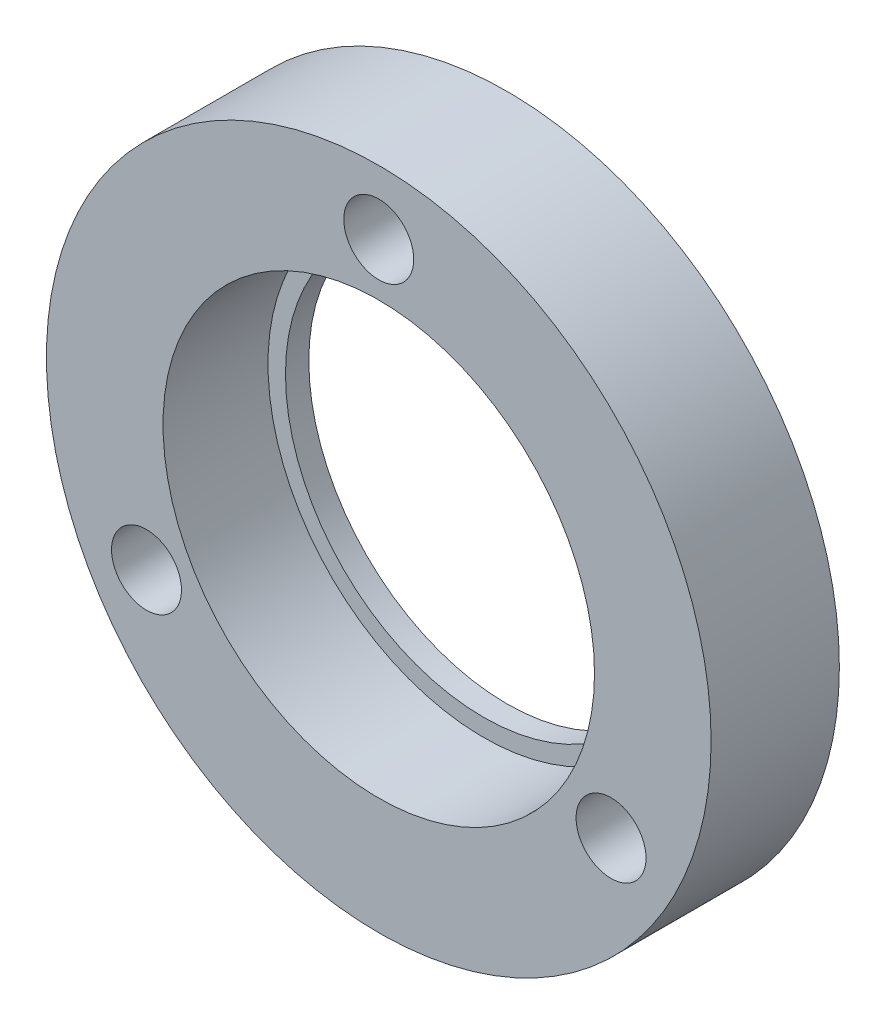
from build123d import *

# Parameters (mm, degrees)
SKETCH_1_R          = 28.5
EXTRUDE_1_DEPTH     = 11
SKETCH_3_R          = 18.5
CUT_EXTRUDE_1_DEPTH = 9
SKETCH_4_R          = 17
CUT_EXTRUDE_2_DEPTH = 3
SKETCH_5_R          = 3
CUT_EXTRUDE_3_DEPTH = 12


with BuildPart() as part:
    # 草图1 → 凸台-拉伸1 (new body)
    with BuildSketch(Plane.XY):
        Circle(SKETCH_1_R)
    extrude(amount=EXTRUDE_1_DEPTH)

    # 草图3 → 切除-拉伸1 (cut)
    with BuildSketch(Plane.XY.offset(11)):
        Circle(SKETCH_3_R)
    extrude(amount=-CUT_EXTRUDE_1_DEPTH, mode=Mode.SUBTRACT)

    # 草图4 → 切除-拉伸2 (cut, through all)
    with BuildSketch(Plane.XY.offset(2)):
        Circle(SKETCH_4_R)
    extrude(amount=-CUT_EXTRUDE_2_DEPTH, mode=Mode.SUBTRACT)

    # 草图5 → 切除-拉伸3 (cut, through all)
    with BuildSketch(Plane.XY.offset(11)):
        with Locations((0, 23)):
            Circle(SKETCH_5_R)
        with Locations((19.918584287, -11.5)):
            Circle(SKETCH_5_R)
        with Locations((-19.918584287, -11.5)):
            Circle(SKETCH_5_R)
    extrude(amount=-CUT_EXTRUDE_3_DEPTH, mode=Mode.SUBTRACT)


solid = part.part
